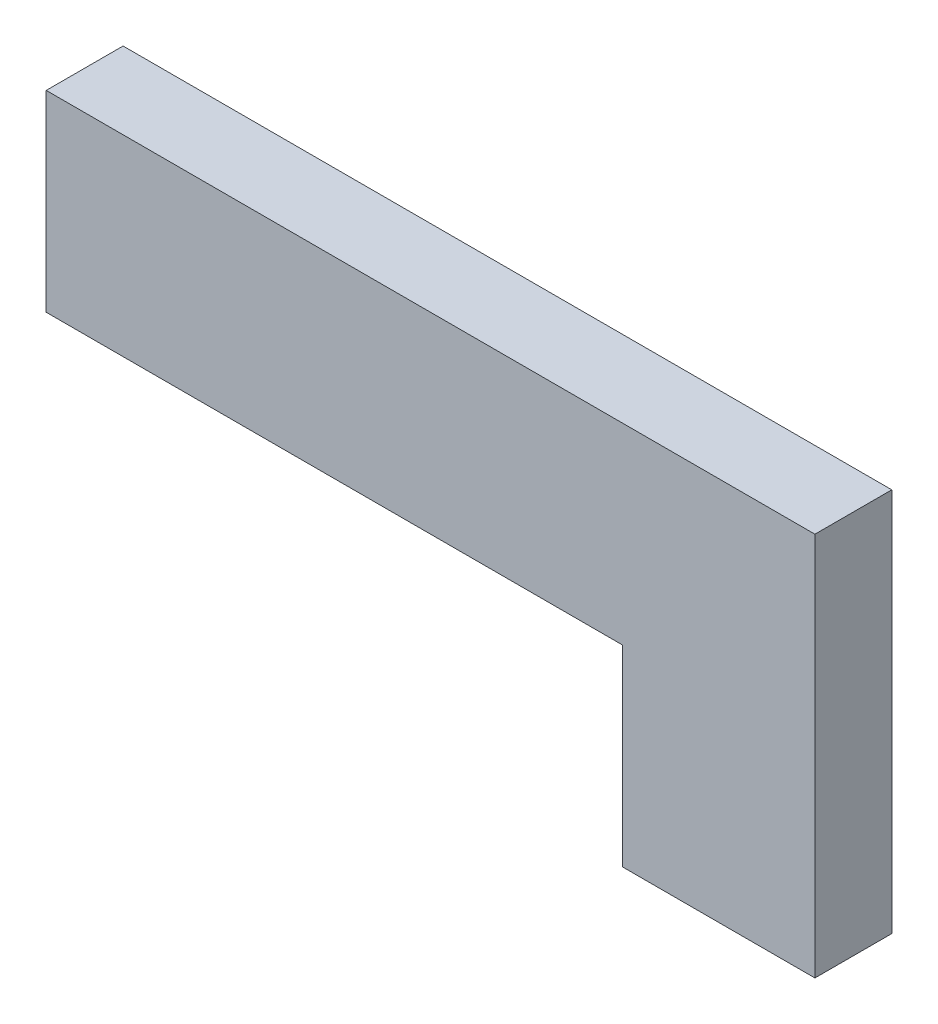
from build123d import *

# Parameters (mm, degrees)
BOSS_EXTRUDE1_DEPTH = 2


with BuildPart() as part:
    # Sketch1 → Boss-Extrude1 (new body)
    with BuildSketch(Plane.XY):
        Polygon((0, 0), (20, 0), (20, -10), (15, -10), (15, -5), (0, -5), align=None)
    extrude(amount=BOSS_EXTRUDE1_DEPTH)


solid = part.part
